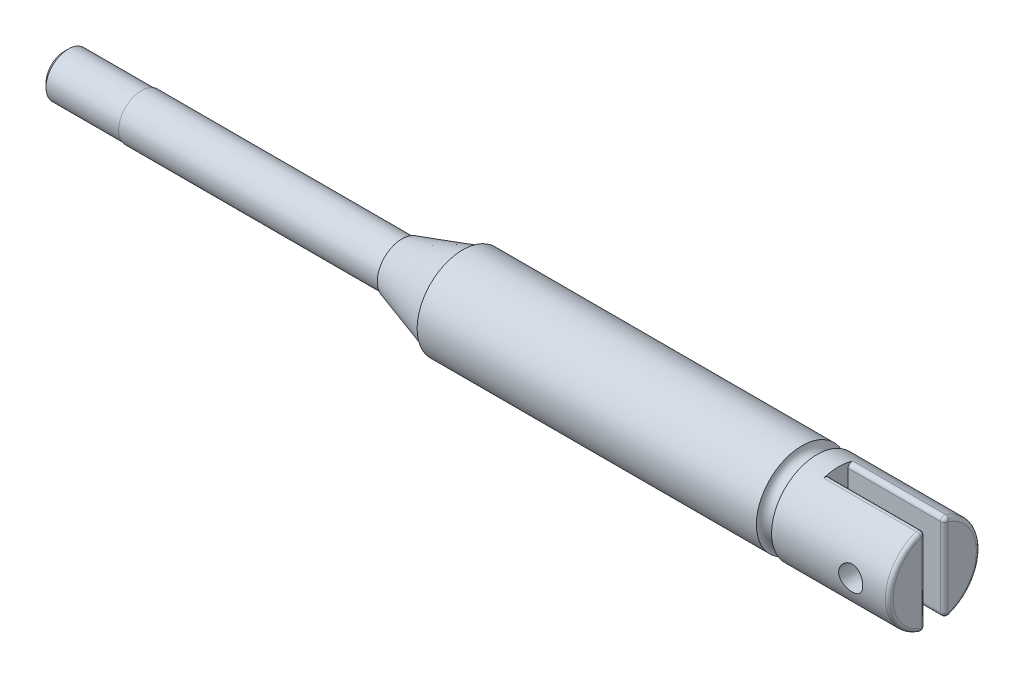
from build123d import *

# Parameters (mm, degrees)
ESQUISSE2_W                  = 12.7
ESQUISSE2_H                  = 1.27
ENL_V_MAT_EXTRU_1_DEPTH      = 4
ENL_V_MAT_EXTRU_1_DEPTH_BACK = 4
ESQUISSE3_R                  = 0.79375
ENL_V_MAT_EXTRU_2_DEPTH      = 4
ENL_V_MAT_EXTRU_2_DEPTH_BACK = 4
ESQUISSE4_W                  = 5.08
ESQUISSE4_H                  = 0.0395
CHANFREIN1_SIZE              = 0.254
CONG_1_R                     = 0.254
ESQUISSE5_R                  = 0.5


with BuildPart() as part:
    # Esquisse1 → Révolution1 (revolve)
    with BuildSketch(Plane.XY):
        Polygon((0, 0), (0, 3), (-31.115, 3), (-31.115, 2.873), (-35.114992, 1.627), (-35.114992, 1.5), (-57.36844, 1.5), (-57.36844, 0), align=None)
    revolve(axis=Axis((-76.031292341, 0, 0), (1, 0, 0)))

    # Esquisse2 → Enlèv. mat.-Extru.1 (cut, two sides)
    with BuildSketch(Plane(origin=(0, 0, 0), x_dir=(1, 0, 0), z_dir=(0, 1, 0))) as enl_v_mat_extru_1_sk:
        Rectangle(ESQUISSE2_W, ESQUISSE2_H)
    extrude(amount=ENL_V_MAT_EXTRU_1_DEPTH, mode=Mode.SUBTRACT)
    extrude(enl_v_mat_extru_1_sk.sketch, amount=-ENL_V_MAT_EXTRU_1_DEPTH_BACK, mode=Mode.SUBTRACT)

    # Esquisse3 → Enlèv. mat.-Extru.2 (cut, two sides)
    with BuildSketch(Plane.XY) as enl_v_mat_extru_2_sk:
        with Locations((-2.54, 0)):
            Circle(ESQUISSE3_R)
    extrude(amount=ENL_V_MAT_EXTRU_2_DEPTH, mode=Mode.SUBTRACT)
    extrude(enl_v_mat_extru_2_sk.sketch, amount=-ENL_V_MAT_EXTRU_2_DEPTH_BACK, mode=Mode.SUBTRACT)

    # Esquisse4 → Enlèvement de matière-Révolution1 (revolve, cut)
    with BuildSketch(Plane.XY):
        with Locations((-54.82844, 1.48025)):
            Rectangle(ESQUISSE4_W, ESQUISSE4_H)
    revolve(axis=Axis((-63.433068243, 0, 0), (1, 0, 0)), mode=Mode.SUBTRACT)

    # Chanfrein1
    chanfrein1_edges = [part.edges().sort_by_distance(p)[0] for p in [
        (-57.36844, -1.4605, 0),
    ]]
    chamfer(chanfrein1_edges, length=CHANFREIN1_SIZE)

    # Congé1
    cong_1_edges = [part.edges().sort_by_distance(p)[0] for p in [
        (0, 0, 3),
        (0, 0, -3),
        (0, 0, -0.635),
        (0, 0, 0.635),
        (-3.175, 2.93202575, 0.635),
        (-3.175, -2.93202575, 0.635),
        (-3.175, -2.93202575, -0.635),
        (-3.175, 2.93202575, -0.635),
    ]]
    fillet(cong_1_edges, radius=CONG_1_R)

    # Esquisse5 → Enlèvement de matière-Révolution2 (revolve, cut)
    with BuildSketch(Plane.XY):
        with Locations((-8.255, 3)):
            Circle(ESQUISSE5_R)
    revolve(axis=Axis((-76.031292341, 0, 0), (-1, 0, 0)), mode=Mode.SUBTRACT)


solid = part.part
